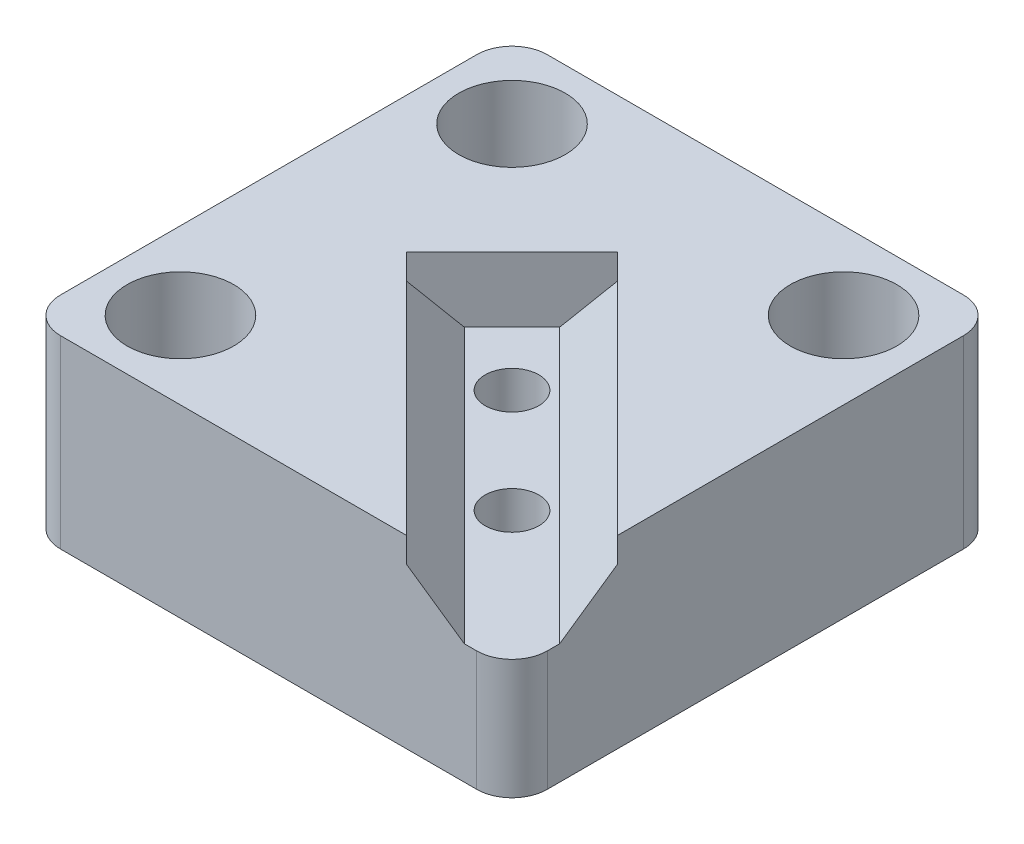
from build123d import *

# Parameters (mm, degrees)
SKETCH1_W       = 52.578
SKETCH1_H       = 52.578
EXTRUDE1_DEPTH  = 19.9644
EXTRUDE2_START  = -19.9644
SKETCH2_R       = 2.667
EXTRUDE2_DEPTH  = 5.7658
EXTRUDE4_START  = -19.9644
SKETCH6_R       = 5.75437
EXTRUDE4_DEPTH  = 14.1986
EXTRUDE6_START  = -45.52216
EXTRUDE6_DEPTH  = 45.52216
EXTRUDE10_START = -12.954
SKETCH15_R      = 2.8956
EXTRUDE10_DEPTH = 7.874
SKETCH16_R      = 5.9055
EXTRUDE11_DEPTH = 5.08
FILLET2_R       = 3.81
SKETCH12_R      = 5.08
EXTRUDE9_DEPTH  = 5.08


with BuildPart() as part:
    # Sketch1 → Extrude1 (new body)
    with BuildSketch(Plane(origin=(0, 0, 0), x_dir=(1, 0, 0), z_dir=(0, 1, 0))):
        Rectangle(SKETCH1_W, SKETCH1_H)
    extrude(amount=EXTRUDE1_DEPTH)

    # Sketch2 → Extrude2 (cut)
    with BuildSketch(Plane(origin=(0, 19.9644, 0), x_dir=(1, 0, 0), z_dir=(0, 1, 0)).offset(EXTRUDE2_START)):
        with Locations((-17.907, 17.907)):
            Circle(SKETCH2_R)
        with Locations((-17.907, -17.907)):
            Circle(SKETCH2_R)
        with Locations((17.907, 17.907)):
            Circle(SKETCH2_R)
    extrude(amount=EXTRUDE2_DEPTH, mode=Mode.SUBTRACT)

    # Sketch6 → Extrude4 (cut)
    with BuildSketch(Plane.XZ.offset(EXTRUDE4_START)):
        with Locations((-17.907, -17.907)):
            Circle(SKETCH6_R)
        with Locations((-17.907, 17.907)):
            Circle(SKETCH6_R)
        with Locations((17.907, -17.907)):
            Circle(SKETCH6_R)
    extrude(amount=EXTRUDE4_DEPTH, mode=Mode.SUBTRACT)

    # Sketch10 → Extrude6 (cut)
    with BuildSketch(Plane(origin=(-5.900028272, 0, -5.900028272), x_dir=(-0.707106781, 0, 0.707106781), z_dir=(-0.707106781, 0, -0.707106781)).offset(EXTRUDE6_START)):
        Polygon((-8.0645, 19.9644), (-8.0645, 17.272), (-3.6449, 12.954), (3.6449, 12.954), (8.0645, 17.272), (8.0645, 19.9644), align=None)
    extrude(amount=EXTRUDE6_DEPTH, mode=Mode.SUBTRACT)

    # Sketch15 → Extrude10 (cut)
    with BuildSketch(Plane.XZ.offset(EXTRUDE10_START)):
        Circle(SKETCH15_R)
        with Locations((11.24204, 11.24204)):
            Circle(SKETCH15_R)
    extrude(amount=EXTRUDE10_DEPTH, mode=Mode.SUBTRACT)

    # Sketch16 → Extrude11 (cut)
    with BuildSketch(Plane.XZ):
        Circle(SKETCH16_R)
        with Locations((11.24204, 11.24204)):
            Circle(SKETCH16_R)
    extrude(amount=-EXTRUDE11_DEPTH, mode=Mode.SUBTRACT)

    # Fillet2
    fillet2_edges = [part.edges().sort_by_distance(p)[0] for p in [
        (26.289, 6.477, 26.289),
        (-26.289, 9.9822, -26.289),
        (26.289, 9.9822, -26.289),
        (-26.289, 9.9822, 26.289),
    ]]
    fillet(fillet2_edges, radius=FILLET2_R)

    # Sketch12 → Extrude9 (cut)
    with BuildSketch(Plane(origin=(0, 19.9644, 0), x_dir=(1, 0, 0), z_dir=(0, 1, 0))):
        Circle(SKETCH12_R)
        with Locations((15.9004, -15.9004)):
            Circle(SKETCH12_R)
    extrude(amount=EXTRUDE9_DEPTH, mode=Mode.SUBTRACT)


solid = part.part
